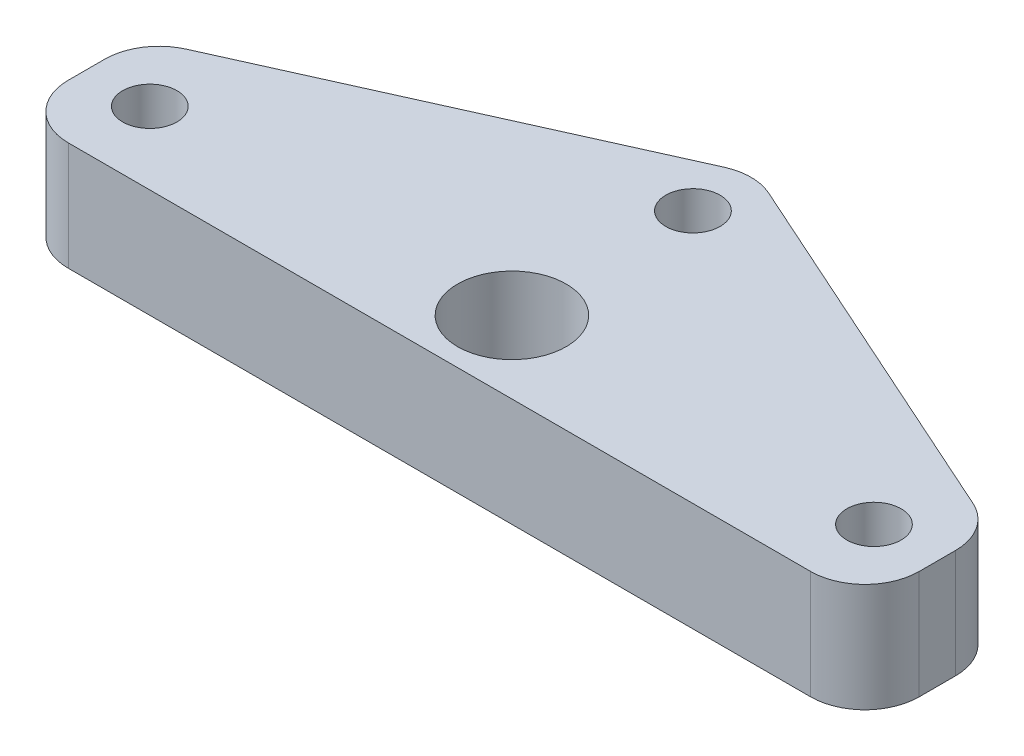
from build123d import *

# Parameters (mm, degrees)
SKETCH1_R           = 3
SKETCH1_R_2         = 1.5
BOSS_EXTRUDE1_DEPTH = 6
FILLET1_R           = 3


with BuildPart() as part:
    # Sketch1 → Boss-Extrude1 (new body)
    with BuildSketch(Plane(origin=(0, 0, 0), x_dir=(1, 0, 0), z_dir=(0, 1, 0))):
        Polygon((23.5, 0), (-23.5, 0), (-23.5, 6.946022727), (0, 17.5), (23.5, 6.946022727), align=None)
        with Locations((0, 4)):
            Circle(SKETCH1_R, mode=Mode.SUBTRACT)
        with Locations((20, 4)):
            Circle(SKETCH1_R_2, mode=Mode.SUBTRACT)
        with Locations((-20, 4)):
            Circle(SKETCH1_R_2, mode=Mode.SUBTRACT)
        with Locations((0, 14)):
            Circle(SKETCH1_R_2, mode=Mode.SUBTRACT)
    extrude(amount=BOSS_EXTRUDE1_DEPTH)

    # Fillet1
    fillet1_edges = [part.edges().sort_by_distance(p)[0] for p in [
        (23.5, 3, 0),
        (-23.5, 3, 0),
        (-23.5, 3, -6.946022727),
        (0, 3, -17.5),
        (23.5, 3, -6.946022727),
    ]]
    fillet(fillet1_edges, radius=FILLET1_R)


solid = part.part
